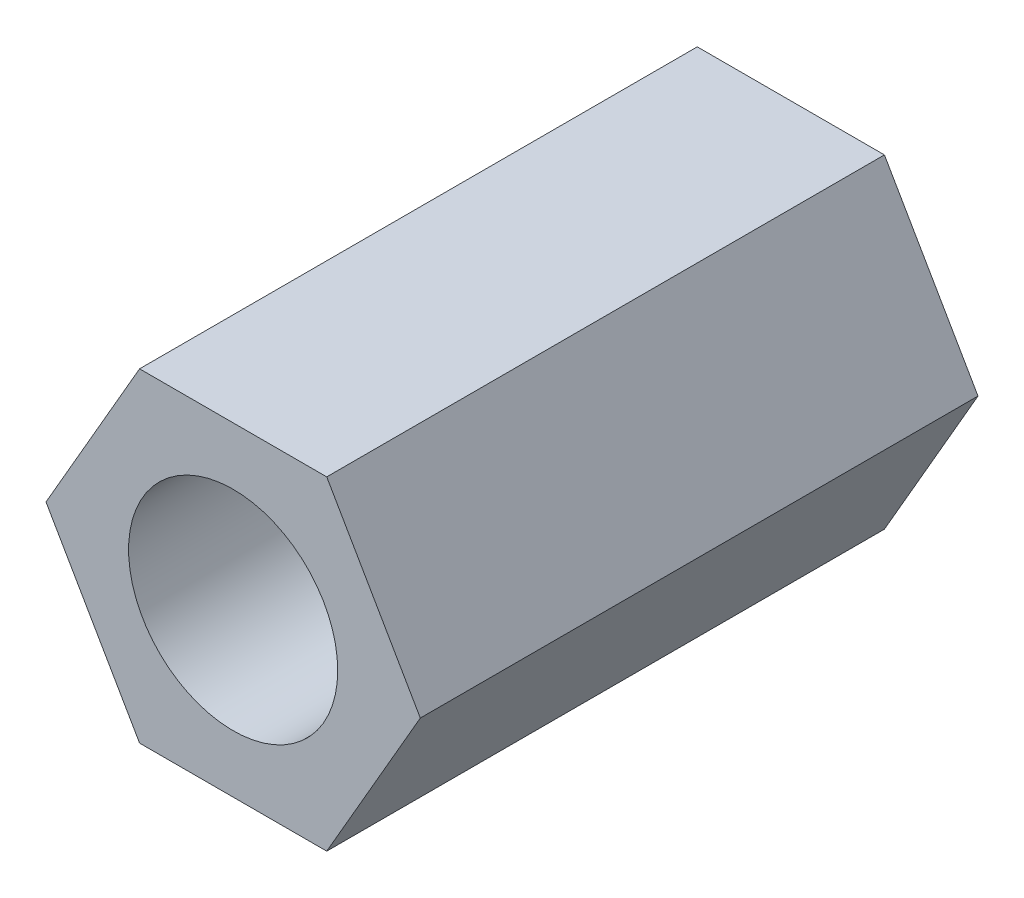
from build123d import *

# Parameters (mm, degrees)
CROQUIS1_R              = 1.5
SALIENTE_EXTRUIR1_DEPTH = 8


with BuildPart() as part:
    # Croquis1 → Saliente-Extruir1 (new body)
    with BuildSketch(Plane.XY):
        Polygon((1.342339376, -2.325), (2.684678752, 0), (1.342339376, 2.325), (-1.342339376, 2.325), (-2.684678752, 0), (-1.342339376, -2.325), align=None)
        Circle(CROQUIS1_R, mode=Mode.SUBTRACT)
    extrude(amount=SALIENTE_EXTRUIR1_DEPTH)


solid = part.part
